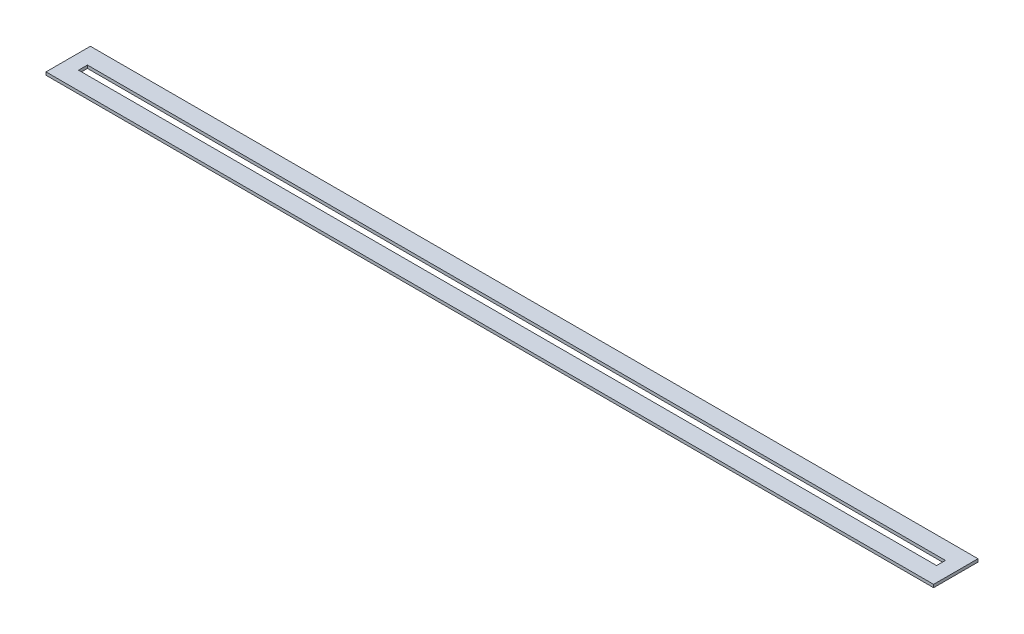
from build123d import *

# Parameters (mm, degrees)
SKETCH1_W           = 600
SKETCH1_H           = 30
SKETCH1_W_2         = 580
SKETCH1_H_2         = 6
BOSS_EXTRUDE1_DEPTH = 2


with BuildPart() as part:
    # Sketch1 → Boss-Extrude1 (new body)
    with BuildSketch(Plane(origin=(0, 0, 0), x_dir=(1, 0, 0), z_dir=(0, 1, 0))):
        with Locations((300, -15)):
            Rectangle(SKETCH1_W, SKETCH1_H)
        with Locations((300, -15)):
            Rectangle(SKETCH1_W_2, SKETCH1_H_2, mode=Mode.SUBTRACT)
    extrude(amount=BOSS_EXTRUDE1_DEPTH)


solid = part.part
